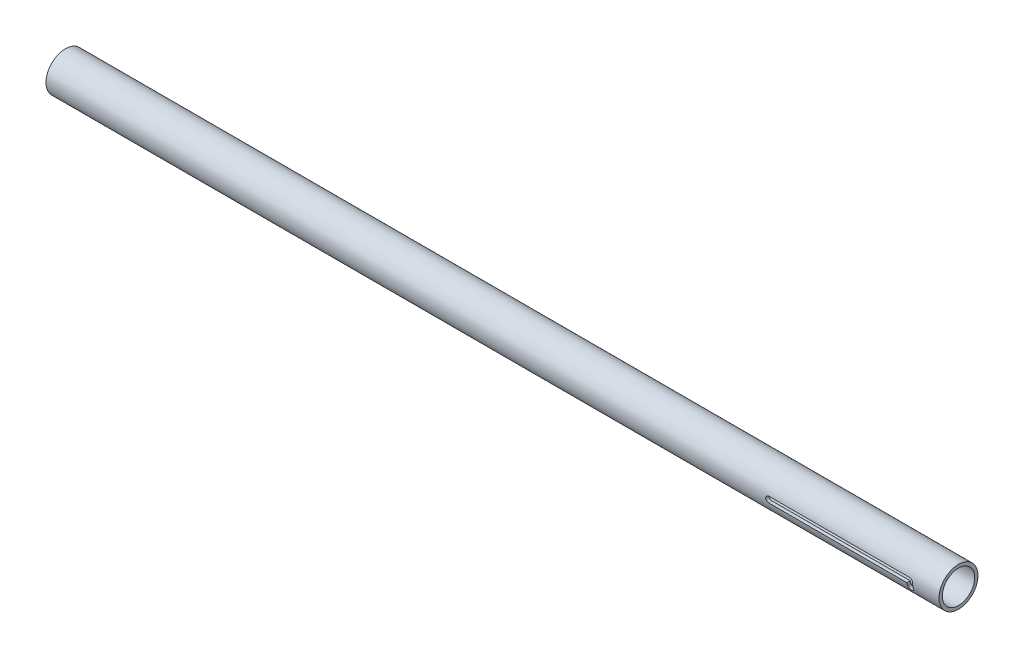
from build123d import *

# Parameters (mm, degrees)
SKETCH1_R           = 21.082
SKETCH1_R_2         = 17.526
BOSS_EXTRUDE1_DEPTH = 965.2
CUT_EXTRUDE1_DEPTH  = 22.082
CUT_EXTRUDE2_DEPTH  = 22.0820001


with BuildPart() as part:
    # Sketch1 → Boss-Extrude1 (new body)
    with BuildSketch(Plane(origin=(0, 0, 0), x_dir=(0, 0, -1), z_dir=(1, 0, 0))):
        Circle(SKETCH1_R)
        Circle(SKETCH1_R_2, mode=Mode.SUBTRACT)
    extrude(amount=BOSS_EXTRUDE1_DEPTH)

    # Sketch2 → Cut-Extrude1 (cut, through all)
    with BuildSketch(Plane.XY):
        with BuildLine():
            Line((7.9375, 3.175), (20.6375, 3.175))
            ThreePointArc((20.6375, 3.175), (23.8125, 0), (20.6375, -3.175))
            Line((20.6375, -3.175), (7.9375, -3.175))
            ThreePointArc((7.9375, -3.175), (4.7625, 0), (7.9375, 3.175))
        make_face()
        with BuildLine():
            Line((46.0375, 3.175), (58.7375, 3.175))
            ThreePointArc((58.7375, 3.175), (61.9125, 0), (58.7375, -3.175))
            Line((58.7375, -3.175), (46.0375, -3.175))
            ThreePointArc((46.0375, -3.175), (42.8625, 0), (46.0375, 3.175))
        make_face()
    extrude(amount=-CUT_EXTRUDE1_DEPTH, mode=Mode.SUBTRACT)

    # Sketch3 → Cut-Extrude2 (cut, through all)
    with BuildSketch(Plane.XY):
        with BuildLine():
            Line((781.05, 3.175), (933.45, 3.175))
            ThreePointArc((933.45, 3.175), (935.69506403, 2.24506403), (936.625, 0))
            Line((936.625, 0), (936.625, -6.35))
            ThreePointArc((936.625, -6.35), (933.45, -9.525), (930.275, -6.35))
            Line((930.275, -6.35), (930.275, -3.175))
            Line((930.275, -3.175), (781.05, -3.175))
            ThreePointArc((781.05, -3.175), (777.875, 0), (781.05, 3.175))
        make_face()
    extrude(amount=CUT_EXTRUDE2_DEPTH, mode=Mode.SUBTRACT)


solid = part.part
